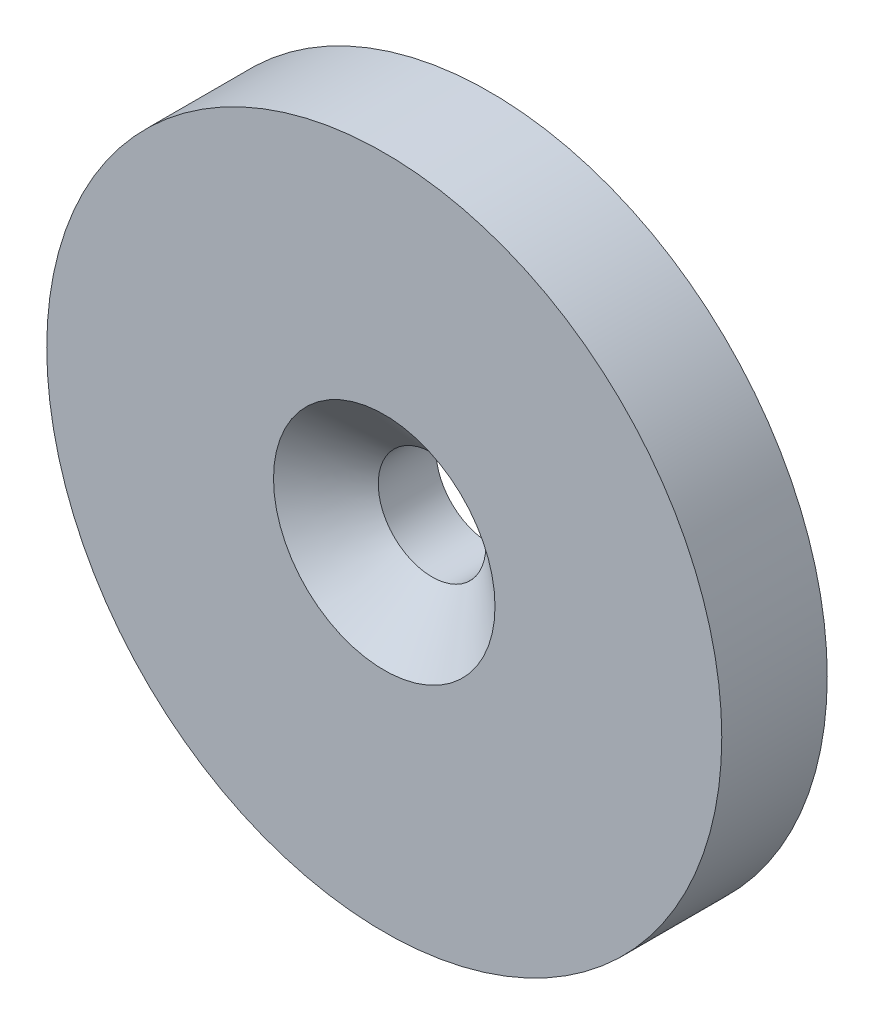
from build123d import *

# Parameters (mm, degrees)
SKETCH1_R                                         = 16
BOSS_EXTRUDE1_DEPTH                               = 5
CSK_FOR_1_FLAT_HEAD_MACHINE_SCREW_100_D           = 5.09999996
CSK_FOR_1_FLAT_HEAD_MACHINE_SCREW_100_CSINK_D     = 10.500000082
CSK_FOR_1_FLAT_HEAD_MACHINE_SCREW_100_CSINK_ANGLE = 100


with BuildPart() as part:
    # Sketch1 → Boss-Extrude1 (new body)
    with BuildSketch(Plane.XY):
        with Locations((-29.503745121, 20.766811092)):
            Circle(SKETCH1_R)
    extrude(amount=BOSS_EXTRUDE1_DEPTH)

    # CSK for #1 Flat Head Machine Screw (100)1 (through all)
    with Locations(Plane(origin=(-29.503745121, 20.766811092, 5), x_dir=(1, 0, 0), z_dir=(0, 0, 1))):
        with Locations((0, 0)):
            CounterSinkHole(CSK_FOR_1_FLAT_HEAD_MACHINE_SCREW_100_D / 2, CSK_FOR_1_FLAT_HEAD_MACHINE_SCREW_100_CSINK_D / 2, counter_sink_angle=CSK_FOR_1_FLAT_HEAD_MACHINE_SCREW_100_CSINK_ANGLE)


solid = part.part
